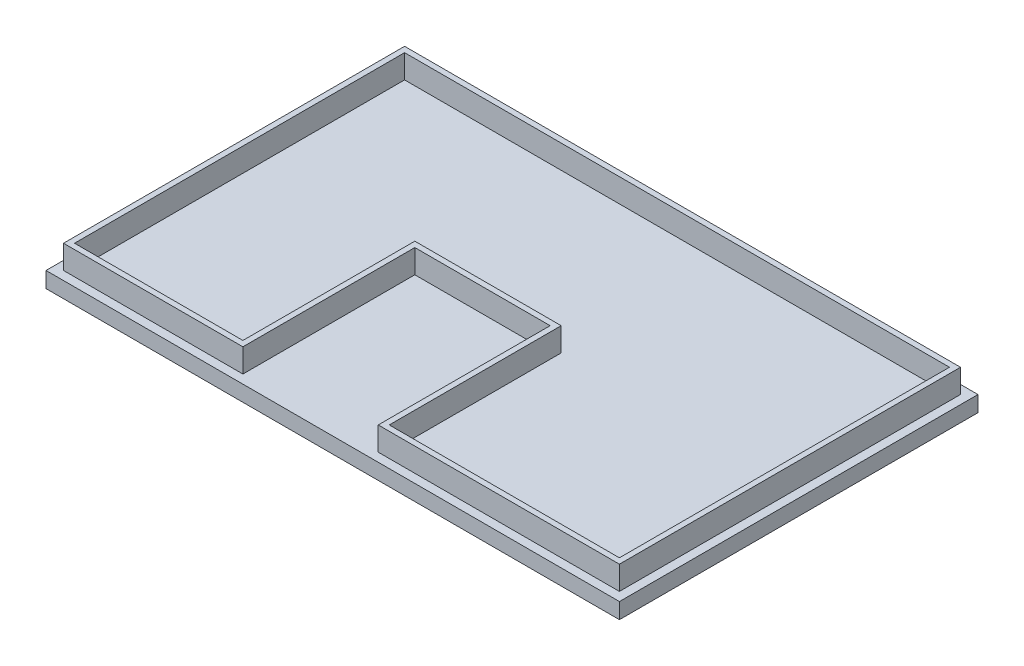
from build123d import *

# Parameters (mm, degrees)
SKETCH1_W           = 185.1152
SKETCH1_H           = 115.7478
BOSS_EXTRUDE1_DEPTH = 5.08
BOSS_EXTRUDE2_DEPTH = 7.62


with BuildPart() as part:
    # Sketch1 → Boss-Extrude1 (new body)
    with BuildSketch(Plane(origin=(0, 0, 0), x_dir=(1, 0, 0), z_dir=(0, 1, 0))):
        with Locations((92.5576, 57.8739)):
            Rectangle(SKETCH1_W, SKETCH1_H)
    extrude(amount=BOSS_EXTRUDE1_DEPTH)

    # Sketch2 → Boss-Extrude2 (add)
    with BuildSketch(Plane(origin=(0, 5.08, 0), x_dir=(1, 0, 0), z_dir=(0, 1, 0))):
        Polygon((2.8321, 112.9284), (182.2831, 112.9284), (182.2831, 2.8194), (104.4321, 2.8194), (104.4321, 58.3184), (60.7441, 58.3184), (60.7441, 2.8194), (2.8321, 2.8194), align=None)
        Polygon((4.6101, 111.1504), (4.6101, 4.5974), (58.9661, 4.5974), (58.9661, 60.0964), (106.2101, 60.0964), (106.2101, 4.5974), (180.5051, 4.5974), (180.5051, 111.1504), align=None, mode=Mode.SUBTRACT)
    extrude(amount=BOSS_EXTRUDE2_DEPTH)


solid = part.part
